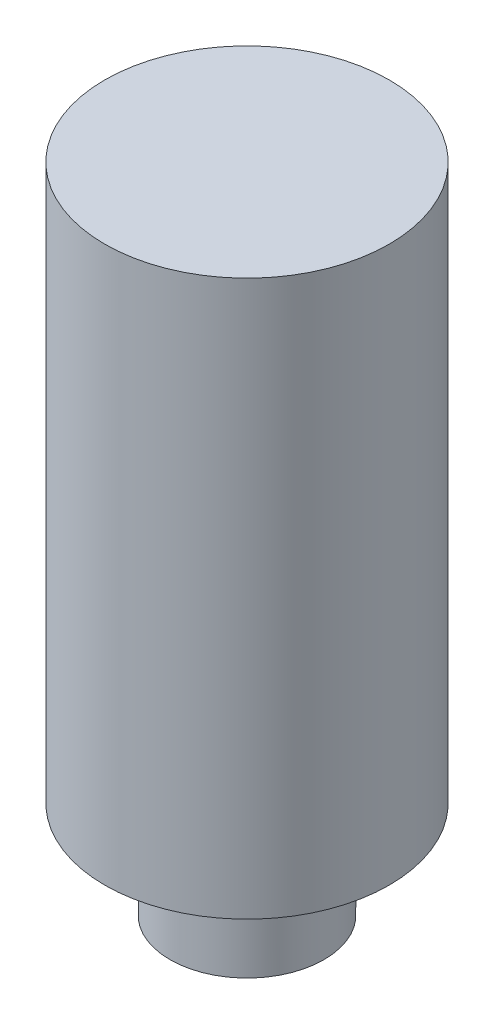
from build123d import *

# Parameters (mm, degrees)
CROQUIS1_R              = 10.25
SALIENTE_EXTRUIR1_DEPTH = 40
CROQUIS2_R              = 5.55
CROQUIS2_R_2            = 2.45
SALIENTE_EXTRUIR2_DEPTH = 7


with BuildPart() as part:
    # Croquis1 → Saliente-Extruir1 (new body)
    with BuildSketch(Plane(origin=(0, 0, 0), x_dir=(1, 0, 0), z_dir=(0, 1, 0))):
        Circle(CROQUIS1_R)
    extrude(amount=SALIENTE_EXTRUIR1_DEPTH)

    # Croquis2 → Saliente-Extruir2 (add)
    with BuildSketch(Plane.XZ):
        Circle(CROQUIS2_R)
        Circle(CROQUIS2_R_2, mode=Mode.SUBTRACT)
    extrude(amount=SALIENTE_EXTRUIR2_DEPTH)


solid = part.part
